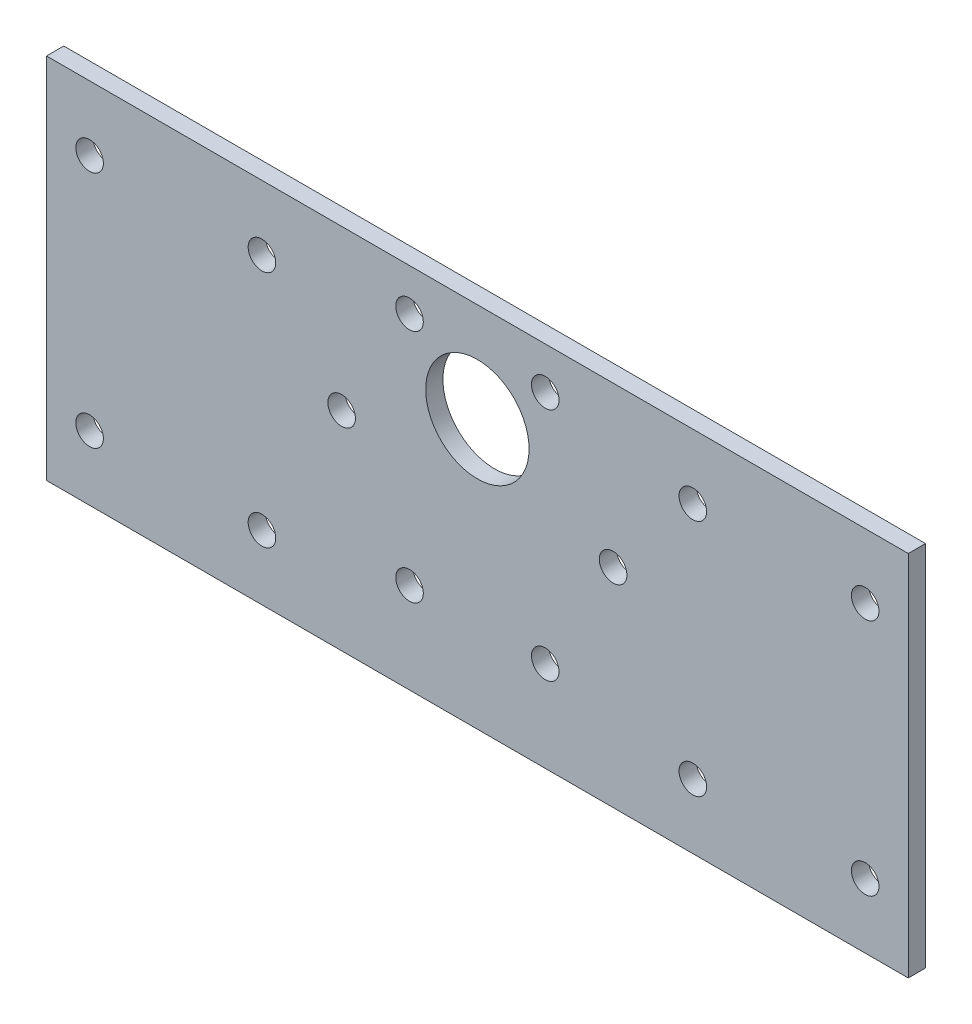
from build123d import *

# Parameters (mm, degrees)
SKETCH_1_W          = 100
SKETCH_1_H          = 50
SKETCH_1_R          = 1.6
EXTRUDE_1_DEPTH     = 2
SKETCH_3_R          = 6
CUT_EXTRUDE_2_DEPTH = 2
SKETCH_4_R          = 1.6
CUT_EXTRUDE_3_DEPTH = 2
CUT_EXTRUDE_7_DEPTH = 3
SKETCH_6_W          = 100
SKETCH_6_H          = 2
CUT_EXTRUDE_8_DEPTH = 7.34
SKETCH_7_R          = 1.6
CUT_EXTRUDE_9_DEPTH = 10


with BuildPart() as part:
    # ｽｹｯﾁ1 → ﾎﾞｽ - 押し出し1 (new body)
    with BuildSketch(Plane.XY):
        Rectangle(SKETCH_1_W, SKETCH_1_H)
        with Locations((-15.75, 6.5)):
            Circle(SKETCH_1_R, mode=Mode.SUBTRACT)
        with Locations((15.75, 6.5)):
            Circle(SKETCH_1_R, mode=Mode.SUBTRACT)
    extrude(amount=EXTRUDE_1_DEPTH)

    # ｽｹｯﾁ3 → ｶｯﾄ - 押し出し2 (cut)
    with BuildSketch(Plane.XY.offset(2)):
        with Locations((0, 13.5)):
            Circle(SKETCH_3_R)
    extrude(amount=-CUT_EXTRUDE_2_DEPTH, mode=Mode.SUBTRACT)

    # ｽｹｯﾁ4 → ｶｯﾄ - 押し出し3 (cut)
    with BuildSketch(Plane.XY.offset(2)):
        with Locations((-7.875, 20.13990011)):
            Circle(SKETCH_4_R)
        with Locations((7.875, 20.13990011)):
            Circle(SKETCH_4_R)
        with Locations((-7.875, -7.13990011)):
            Circle(SKETCH_4_R)
        with Locations((7.875, -7.13990011)):
            Circle(SKETCH_4_R)
    extrude(amount=-CUT_EXTRUDE_3_DEPTH, mode=Mode.SUBTRACT)

    # ｽｹｯﾁ5 → ｶｯﾄ - 押し出し7 (cut, through all)
    with BuildSketch(Plane.XY.offset(2)):
        with BuildLine():
            ThreePointArc((-46.6, -10.16), (-45, -11.76), (-43.4, -10.16))
            Line((-43.4, -10.16), (-45, -10.16))
            Line((-45, -10.16), (-46.6, -10.16))
        make_face()
        with BuildLine():
            Line((-45, -10.16), (-43.4, -10.16))
            ThreePointArc((-43.4, -10.16), (-45, -8.56), (-46.6, -10.16))
            Line((-46.6, -10.16), (-45, -10.16))
        make_face()
        with BuildLine():
            ThreePointArc((-26.6, -10.16), (-25, -11.76), (-23.4, -10.16))
            Line((-23.4, -10.16), (-25, -10.16))
            Line((-25, -10.16), (-26.6, -10.16))
        make_face()
        with BuildLine():
            Line((-25, -10.16), (-23.4, -10.16))
            ThreePointArc((-23.4, -10.16), (-25, -8.56), (-26.6, -10.16))
            Line((-26.6, -10.16), (-25, -10.16))
        make_face()
        with BuildLine():
            ThreePointArc((46.6, -10.16), (45, -8.56), (43.4, -10.16))
            Line((43.4, -10.16), (45, -10.16))
            Line((45, -10.16), (46.6, -10.16))
        make_face()
        with BuildLine():
            Line((45, -10.16), (43.4, -10.16))
            ThreePointArc((43.4, -10.16), (45, -11.76), (46.6, -10.16))
            Line((46.6, -10.16), (45, -10.16))
        make_face()
        with BuildLine():
            ThreePointArc((26.6, -10.16), (25, -8.56), (23.4, -10.16))
            Line((23.4, -10.16), (25, -10.16))
            Line((25, -10.16), (26.6, -10.16))
        make_face()
        with BuildLine():
            Line((25, -10.16), (23.4, -10.16))
            ThreePointArc((23.4, -10.16), (25, -11.76), (26.6, -10.16))
            Line((26.6, -10.16), (25, -10.16))
        make_face()
    extrude(amount=-CUT_EXTRUDE_7_DEPTH, mode=Mode.SUBTRACT)

    # ｽｹｯﾁ6 → ｶｯﾄ - 押し出し8 (cut)
    with BuildSketch(Plane.XZ.offset(25)):
        with Locations((0, 1)):
            Rectangle(SKETCH_6_W, SKETCH_6_H)
    extrude(amount=-CUT_EXTRUDE_8_DEPTH, mode=Mode.SUBTRACT)

    # ｽｹｯﾁ7 → ｶｯﾄ - 押し出し9 (cut)
    with BuildSketch(Plane.XY.offset(2)):
        with Locations((-45, 17.5)):
            Circle(SKETCH_7_R)
        with Locations((-25, 17.5)):
            Circle(SKETCH_7_R)
        with Locations((45, 17.5)):
            Circle(SKETCH_7_R)
        with Locations((25, 17.5)):
            Circle(SKETCH_7_R)
    extrude(amount=-CUT_EXTRUDE_9_DEPTH, mode=Mode.SUBTRACT)


solid = part.part
